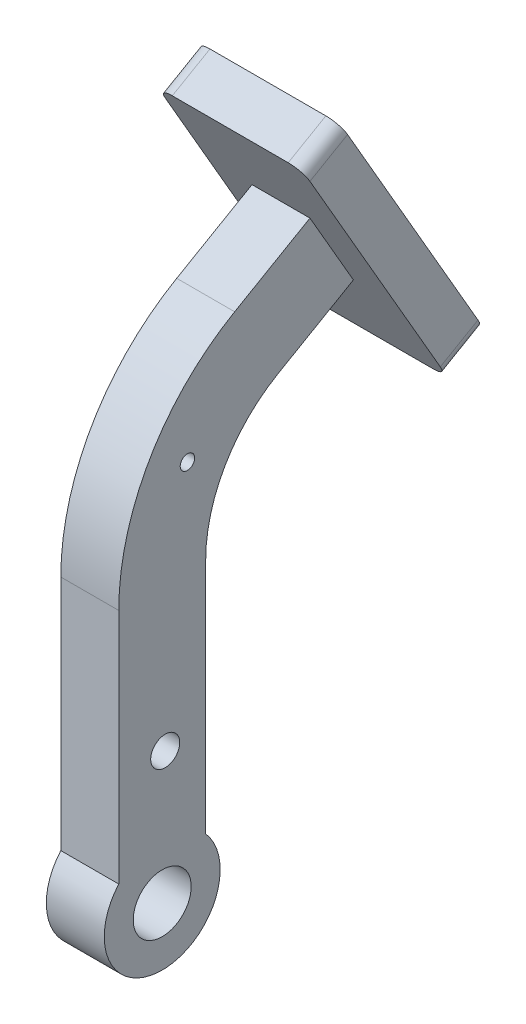
from build123d import *

# Parameters (mm, degrees)
SKETCH3_R           = 10
SKETCH3_R_2         = 5
SKETCH3_R_3         = 2.5
BOSS_EXTRUDE1_DEPTH = 10
BOSS_EXTRUDE2_DEPTH = 25
FILLET1_R           = 5
BOSS_EXTRUDE4_DEPTH = 2
FILLET6_R           = 1


with BuildPart() as part:
    # Sketch3 → Boss-Extrude1 (new, symmetric)
    with BuildSketch(Plane(origin=(0, 0, 0), x_dir=(0, 0, -1), z_dir=(1, 0, 0))):
        with BuildLine():
            Line((65.980762114, 153.301270189), (50.980762114, 179.282032303))
            Line((50.980762114, 179.282032303), (25, 164.282032303))
            ThreePointArc((25, 164.282032303), (-4.282032303, 135), (-15, 95))
            Line((-15, 95), (-15, 13.228756555))
            ThreePointArc((-15, 13.228756555), (0, -20), (15, 13.228756555))
            Line((15, 13.228756555), (15, 95))
            ThreePointArc((15, 95), (21.698729811, 120), (40, 138.301270189))
            Line((40, 138.301270189), (65.980762114, 153.301270189))
        make_face()
        Circle(SKETCH3_R, mode=Mode.SUBTRACT)
        with Locations((1.032464383, 45)):
            Circle(SKETCH3_R_2, mode=Mode.SUBTRACT)
        with Locations((8.708348754, 127.5)):
            Circle(SKETCH3_R_3, mode=Mode.SUBTRACT)
    extrude(amount=BOSS_EXTRUDE1_DEPTH, both=True)

    # Sketch3_3 → Boss-Extrude2 (add, symmetric)
    with BuildSketch(Plane(origin=(0, 0, 0), x_dir=(0, 0, -1), z_dir=(1, 0, 0))):
        Polygon((96.47114317, 130.490381057), (46.47114317, 217.092921435), (33.480762114, 209.592921435), (50.980762114, 179.282032303), (65.980762114, 153.301270189), (83.480762114, 122.990381057), align=None)
    extrude(amount=BOSS_EXTRUDE2_DEPTH, both=True)

    # Fillet1
    fillet1_edges = [part.edges().sort_by_distance(p)[0] for p in [
        (25, 213.342921435, -39.975952642),
        (-25, 213.342921435, -39.975952642),
        (-25, 126.740381057, -89.975952642),
        (25, 126.740381057, -89.975952642),
    ]]
    fillet(fillet1_edges, radius=FILLET1_R)

    # Sketch6 → Boss-Extrude4 (add)
    with BuildSketch(Plane(origin=(0, 74.395825623, -128.85734985), x_dir=(-1, 0, 0), z_dir=(0, 0.4999999999999983, -0.8660254037844397))):
        with BuildLine():
            Line((-5, 149.77241336), (-5, 79.77241336))
            ThreePointArc((-5, 79.77241336), (-10, 74.77241336), (-15, 79.77241336))
            Line((-15, 79.77241336), (-15, 149.77241336))
            ThreePointArc((-15, 149.77241336), (-10, 154.77241336), (-5, 149.77241336))
        make_face()
        with BuildLine():
            Line((15, 149.77241336), (15, 79.77241336))
            ThreePointArc((15, 79.77241336), (10, 74.77241336), (5, 79.77241336))
            Line((5, 79.77241336), (5, 149.77241336))
            ThreePointArc((5, 149.77241336), (10, 154.77241336), (15, 149.77241336))
        make_face()
    extrude(amount=BOSS_EXTRUDE4_DEPTH)

    # Fillet6
    fillet6_edges = [part.edges().sort_by_distance(p)[0] for p in [
        (-10, 209.432667397, -53.203193978),
        (-15, 174.791651246, -73.203193978),
        (-10, 140.150635095, -93.203193978),
        (10, 209.432667397, -53.203193978),
        (5, 174.791651246, -73.203193978),
        (10, 140.150635095, -93.203193978),
        (-5, 174.791651246, -73.203193978),
        (15, 174.791651246, -73.203193978),
    ]]
    fillet(fillet6_edges, radius=FILLET6_R)


solid = part.part
